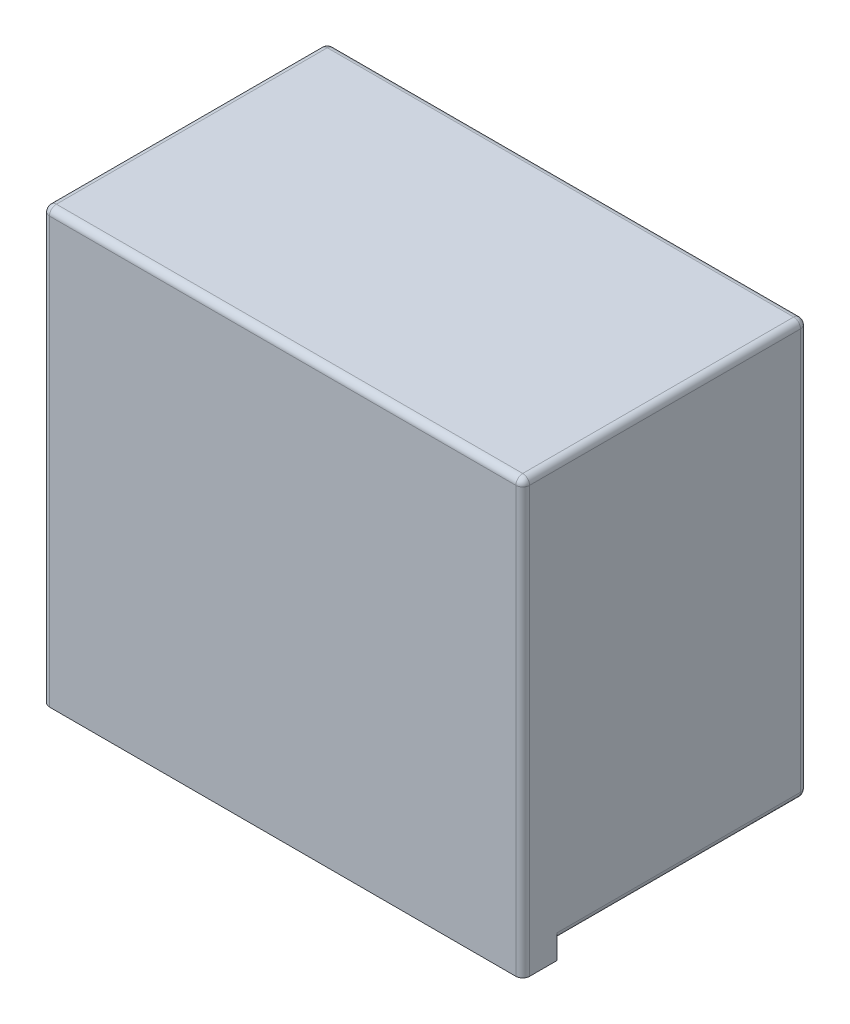
from build123d import *

# Parameters (mm, degrees)
SKETCH1_W          = 14
SKETCH1_H          = 12.6
EXTRUDE1_DEPTH     = 8.3
SKETCH2_R          = 4.75
CUT_EXTRUDE1_DEPTH = 7.3
FILLET1_R          = 0.5
SKETCH3_W          = 9.2
SKETCH3_H          = 0.789398471
SKETCH3_W_2        = 2.03522765
SKETCH3_W_3        = 1.728148887
SKETCH3_H_2        = 1.147657029
CUT_EXTRUDE2_DEPTH = 7.3
FILLET2_R          = 0.5
EXTRUDE2_DEPTH     = 7.3
SKETCH5_W          = 1.5
SKETCH5_H          = 2.2
SKETCH5_R          = 0.3
CUT_EXTRUDE3_DEPTH = 7.3
CHAMFER1_SIZE      = 0.4
FILLET3_R          = 0.2


with BuildPart() as part:
    # Sketch1 → Extrude1 (new body)
    with BuildSketch(Plane.XY):
        with Locations((7, 6.3)):
            Rectangle(SKETCH1_W, SKETCH1_H)
    extrude(amount=EXTRUDE1_DEPTH)

    # Sketch2 → Cut-Extrude1 (cut)
    with BuildSketch(Plane(origin=(0, 0, 0), x_dir=(-1, 0, 0), z_dir=(0, 0, -1))):
        with Locations((-7, 6.15)):
            Circle(SKETCH2_R)
    extrude(amount=-CUT_EXTRUDE1_DEPTH, mode=Mode.SUBTRACT)

    # Fillet1
    fillet1_edges = [part.edges().sort_by_distance(p)[0] for p in [
        (11.75, 6.15, 0),
    ]]
    fillet(fillet1_edges, radius=FILLET1_R)

    # Sketch3 → Cut-Extrude2 (cut)
    with BuildSketch(Plane(origin=(0, 0, 0), x_dir=(-1, 0, 0), z_dir=(0, 0, -1))):
        with Locations((-7, 0.105300765)):
            Rectangle(SKETCH3_W, SKETCH3_H)
        with Locations((0.017613825, 0.105300765)):
            Rectangle(SKETCH3_W_2, SKETCH3_H)
        with Locations((-13.864074444, -0.073828514)):
            Rectangle(SKETCH3_W_3, SKETCH3_H_2)
    extrude(amount=-CUT_EXTRUDE2_DEPTH, mode=Mode.SUBTRACT)

    # Fillet2
    fillet2_edges = [part.edges().sort_by_distance(p)[0] for p in [
        (1.7, 0, 0),
        (12.3, 0, 0),
    ]]
    fillet(fillet2_edges, radius=FILLET2_R)

    # Fillet3
    fillet3_edges = [part.edges().sort_by_distance(p)[0] for p in [
        (14, 6.3, 8.3),
        (7, 12.6, 8.3),
        (0.5, 0.5, 0),
        (0, 0.5, 3.65),
        (0, 6.3, 8.3),
        (7, 12.6, 0),
        (7, 0.5, 0),
        (0, 6.55, 0),
        (14, 6.55, 0),
        (13.5, 0.5, 0),
        (14, 0.5, 3.65),
        (0, 12.6, 4.15),
        (14, 12.6, 4.15),
    ]]
    fillet(fillet3_edges, radius=FILLET3_R)


with BuildPart() as body_2:
    # Sketch4 → Extrude2 (new body)
    with BuildSketch(Plane(origin=(0, 0, 0), x_dir=(-1, 0, 0), z_dir=(0, 0, -1))):
        with BuildLine():
            Line((-10.524202037, 4.6), (-9.35, 4.6))
            Line((-9.35, 4.6), (-9.35, 3.100409864))
            ThreePointArc((-9.35, 3.100409864), (-7, 2.3), (-4.65, 3.100409864))
            Line((-4.65, 3.100409864), (-4.65, 4.6))
            Line((-4.65, 4.6), (-3.475797963, 4.6))
            ThreePointArc((-3.475797963, 4.6), (-3.550620396, 7.860052733), (-6.1, 9.893327397))
            Line((-6.1, 9.893327397), (-6.1, 9.3))
            Line((-6.1, 9.3), (-7.9, 9.3))
            Line((-7.9, 9.3), (-7.9, 9.893327397))
            ThreePointArc((-7.9, 9.893327397), (-10.449379604, 7.860052733), (-10.524202037, 4.6))
        make_face()
    extrude(amount=-EXTRUDE2_DEPTH)

    # Sketch5 → Cut-Extrude3 (cut)
    with BuildSketch(Plane(origin=(0, 0, 0), x_dir=(-1, 0, 0), z_dir=(0, 0, -1))):
        with Locations((-7, 7.4)):
            Rectangle(SKETCH5_W, SKETCH5_H)
        with Locations((-4.671319375, 8.001728149)):
            Circle(SKETCH5_R)
        with Locations((-4.261881024, 5.775407112)):
            Circle(SKETCH5_R)
        with Locations((-9.328680625, 8.001728149)):
            Circle(SKETCH5_R)
        with Locations((-9.738118976, 5.775407112)):
            Circle(SKETCH5_R)
        with Locations((-8.228315055, 3.753805251)):
            Circle(SKETCH5_R)
        with Locations((-5.771684945, 3.753805251)):
            Circle(SKETCH5_R)
    extrude(amount=-CUT_EXTRUDE3_DEPTH, mode=Mode.SUBTRACT)

    # Chamfer1
    chamfer1_edges = [body_2.edges().sort_by_distance(p)[0] for p in [
        (4.971319375, 8.001728149, 0),
        (4.561881024, 5.775407112, 0),
        (9.628680625, 8.001728149, 0),
        (10.038118976, 5.775407112, 0),
        (8.528315055, 3.753805251, 0),
        (6.071684945, 3.753805251, 0),
    ]]
    chamfer(chamfer1_edges, length=CHAMFER1_SIZE)


solid = Compound([part.part, body_2.part])
